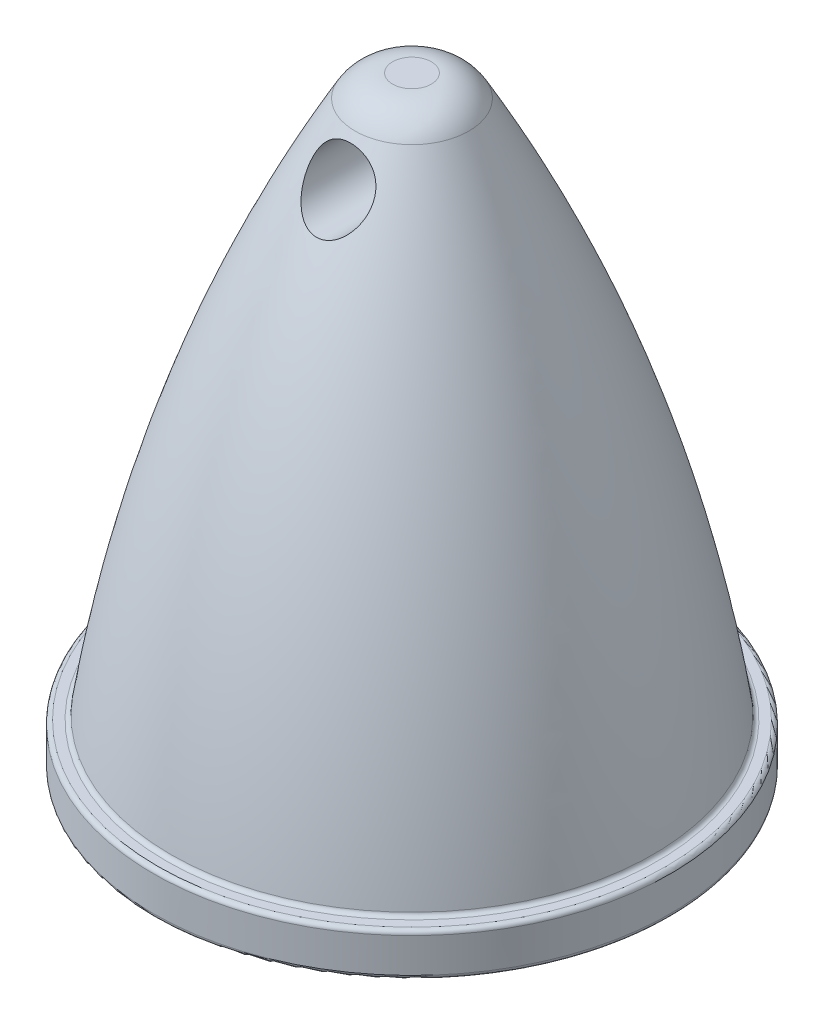
from build123d import *

# Parameters (mm, degrees)
SKETCH2_R               = 1.10372573
CUT_EXTRUDE1_DEPTH      = 1
FILLET1_R               = 1
SKETCH3_R               = 0.75
CUT_EXTRUDE2_DEPTH      = 10
CUT_EXTRUDE2_DEPTH_BACK = 3
FILLET2_R               = 0.1
SKETCH4_R               = 3
CUT_EXTRUDE3_DEPTH      = 10


with BuildPart() as part:
    # Sketch1 → Revolve1 (revolve)
    with BuildSketch(Plane.XY):
        with BuildLine():
            Line((0, 0), (0, 15))
            Line((0, 15), (-0.422259829, 15))
            add(Edge.make_bspline(
                [(-5.608753273, 1), (-4.474708876, 8.543704993), (-0.422259829, 15)],
                knots=[0, 0, 0, 1, 1, 1], degree=2))
            Line((-5.608753273, 1), (-6, 1))
            Line((-6, 1), (-6, 0))
            Line((-6, 0), (0, 0))
        make_face()
    revolve(axis=Axis((0, 0, 0), (0, 1, 0)))

    # Sketch2 → Cut-Extrude1 (cut)
    with BuildSketch(Plane(origin=(0, 15, 0), x_dir=(1, 0, 0), z_dir=(0, 1, 0))):
        Circle(SKETCH2_R)
    extrude(amount=-CUT_EXTRUDE1_DEPTH, mode=Mode.SUBTRACT)

    # Fillet1
    fillet1_edges = [part.edges().sort_by_distance(p)[0] for p in [
        (1.028614291, 14, 1.9e-08),
    ]]
    fillet(fillet1_edges, radius=FILLET1_R)

    # Sketch3 → Cut-Extrude2 (cut, two sides)
    with BuildSketch(Plane.XY) as cut_extrude2_sk:
        with Locations((0, 12.554053904)):
            Circle(SKETCH3_R)
    extrude(amount=CUT_EXTRUDE2_DEPTH, mode=Mode.SUBTRACT)
    extrude(cut_extrude2_sk.sketch, amount=-CUT_EXTRUDE2_DEPTH_BACK, mode=Mode.SUBTRACT)

    # Fillet2
    fillet2_edges = [part.edges().sort_by_distance(p)[0] for p in [
        (6, 0, 0),
        (6, 1, 0),
        (5.608753273, 1, 0),
    ]]
    fillet(fillet2_edges, radius=FILLET2_R)

    # Sketch4 → Cut-Extrude3 (cut)
    with BuildSketch(Plane.XZ):
        Circle(SKETCH4_R)
    extrude(amount=-CUT_EXTRUDE3_DEPTH, mode=Mode.SUBTRACT)


solid = part.part
